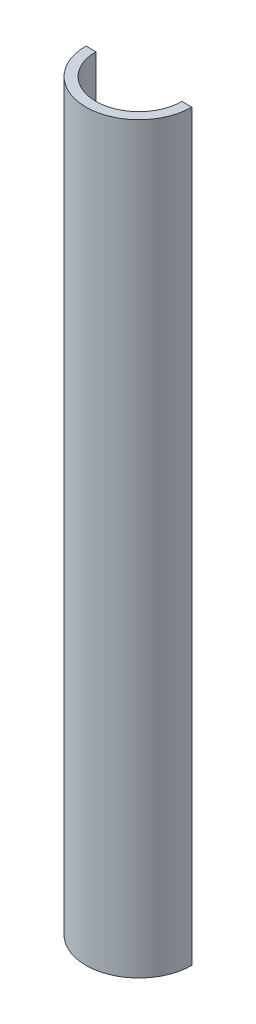
from build123d import *

# Parameters (mm, degrees)
SKETCH2_R               = 21.36
BOSS_EXTRUDE1_DEPTH     = 300
SHELL1_T                = -4
SKETCH3_W               = 54.462291246
SKETCH3_H               = 357.024978236
CUT_EXTRUDE1_DEPTH      = 302.516996536
CUT_EXTRUDE1_DEPTH_BACK = 302.516996536


with BuildPart() as part:
    # Sketch2 → Boss-Extrude1 (new body)
    with BuildSketch(Plane(origin=(0, 0, 0), x_dir=(1, 0, 0), z_dir=(0, 1, 0))):
        with Locations(Location((0, 0, 0), (0, 0, 270))):
            Circle(SKETCH2_R)
    extrude(amount=BOSS_EXTRUDE1_DEPTH)

    # Shell1
    shell1_openings = [part.faces().sort_by_distance(p)[0] for p in [
        (0, 300, 0),
        (0, 0, 0),
    ]]
    offset(amount=SHELL1_T, openings=shell1_openings, kind=Kind.INTERSECTION)

    # Sketch3 → Cut-Extrude1 (cut, two sides)
    with BuildSketch(Plane(origin=(0, 0, 0), x_dir=(0, 0, -1), z_dir=(1, 0, 0))) as cut_extrude1_sk:
        with Locations((27.231145623, 138.076503498)):
            Rectangle(SKETCH3_W, SKETCH3_H)
    extrude(amount=CUT_EXTRUDE1_DEPTH, mode=Mode.SUBTRACT)
    extrude(cut_extrude1_sk.sketch, amount=-CUT_EXTRUDE1_DEPTH_BACK, mode=Mode.SUBTRACT)


solid = part.part
